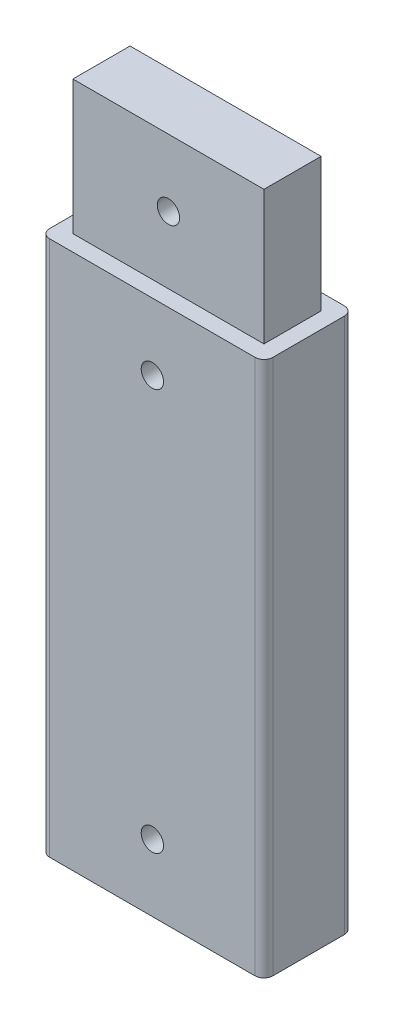
from build123d import *

# Parameters (mm, degrees)
BOSS_EXTRUDE1_DEPTH = 120
SKETCH3_W           = 42
SKETCH3_H           = 12
CUT_EXTRUDE2_DEPTH  = 30
SKETCH6_R           = 2.5
CUT_EXTRUDE3_DEPTH  = 30
SKETCH8_W           = 42.8
SKETCH8_H           = 12.8
BOSS_EXTRUDE2_DEPTH = 30
SKETCH9_R           = 2.5
CUT_EXTRUDE4_DEPTH  = 30


with BuildPart() as part:
    # Sketch1 → Boss-Extrude1 (new body)
    with BuildSketch(Plane(origin=(0, 0, 0), x_dir=(1, 0, 0), z_dir=(0, 1, 0))):
        with BuildLine():
            Line((2, 0), (48, 0))
            ThreePointArc((48, 0), (49.414213562, 0.585786438), (50, 2))
            Line((50, 2), (50, 18))
            ThreePointArc((50, 18), (49.414213562, 19.414213562), (48, 20))
            Line((48, 20), (2, 20))
            ThreePointArc((2, 20), (0.585786438, 19.414213562), (0, 18))
            Line((0, 18), (0, 2))
            ThreePointArc((0, 2), (0.585786438, 0.585786438), (2, 0))
        make_face()
    extrude(amount=BOSS_EXTRUDE1_DEPTH)

    # Sketch3 → Cut-Extrude2 (cut)
    with BuildSketch(Plane.XZ):
        with Locations((25, -10)):
            Rectangle(SKETCH3_W, SKETCH3_H)
    extrude(amount=-CUT_EXTRUDE2_DEPTH, mode=Mode.SUBTRACT)

    # Sketch6 → Cut-Extrude3 (cut)
    with BuildSketch(Plane.XY):
        with Locations((25, 105)):
            Circle(SKETCH6_R)
        with Locations((25, 15)):
            Circle(SKETCH6_R)
    extrude(amount=-CUT_EXTRUDE3_DEPTH, mode=Mode.SUBTRACT)

    # Sketch8 → Boss-Extrude2 (add)
    with BuildSketch(Plane(origin=(0, 120, 0), x_dir=(1, 0, 0), z_dir=(0, 1, 0))):
        with Locations((25, 10)):
            Rectangle(SKETCH8_W, SKETCH8_H)
    extrude(amount=BOSS_EXTRUDE2_DEPTH)

    # Sketch9 → Cut-Extrude4 (cut)
    with BuildSketch(Plane.XY.offset(-3.6)):
        with Locations((25, 135)):
            Circle(SKETCH9_R)
    extrude(amount=-CUT_EXTRUDE4_DEPTH, mode=Mode.SUBTRACT)


solid = part.part
